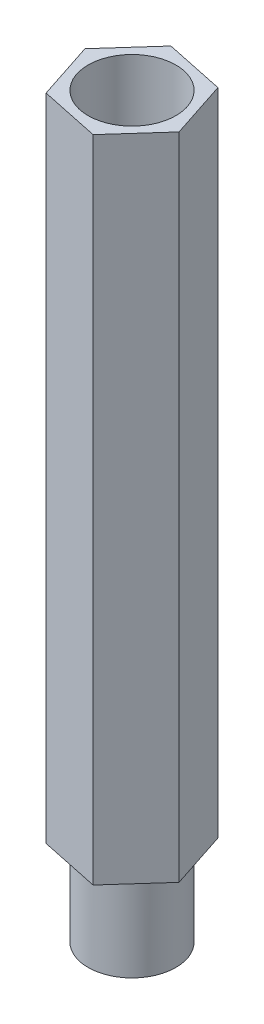
from build123d import *

# Parameters (mm, degrees)
BOSS_EXTRUDE1_DEPTH      = 18.5
SKETCH2_R                = 1.25
CUT_EXTRUDE1_DEPTH       = 18.5
SKETCH3_R                = 1.25
BOSS_EXTRUDE2_DEPTH      = 2.5
BOSS_EXTRUDE2_DEPTH_BACK = 2.5


with BuildPart() as part:
    # Sketch1 → Boss-Extrude1 (new body)
    with BuildSketch(Plane(origin=(0, 0, 0), x_dir=(1, 0, 0), z_dir=(0, 1, 0))):
        Polygon((1.156221884, 1.289632101), (-0.538743219, 1.646133574), (-1.694965103, 0.356501473), (-1.156221884, -1.289632101), (0.538743219, -1.646133574), (1.694965103, -0.356501473), align=None)
    extrude(amount=BOSS_EXTRUDE1_DEPTH)

    # Sketch2 → Cut-Extrude1 (cut)
    with BuildSketch(Plane(origin=(0, 18.5, 0), x_dir=(1, 0, 0), z_dir=(0, 1, 0))):
        Circle(SKETCH2_R)
    extrude(amount=-CUT_EXTRUDE1_DEPTH, mode=Mode.SUBTRACT)

    # Sketch3 → Boss-Extrude2 (add, two sides)
    with BuildSketch(Plane.XZ) as boss_extrude2_sk:
        Circle(SKETCH3_R)
    extrude(amount=BOSS_EXTRUDE2_DEPTH)
    extrude(boss_extrude2_sk.sketch, amount=-BOSS_EXTRUDE2_DEPTH_BACK)


solid = part.part
